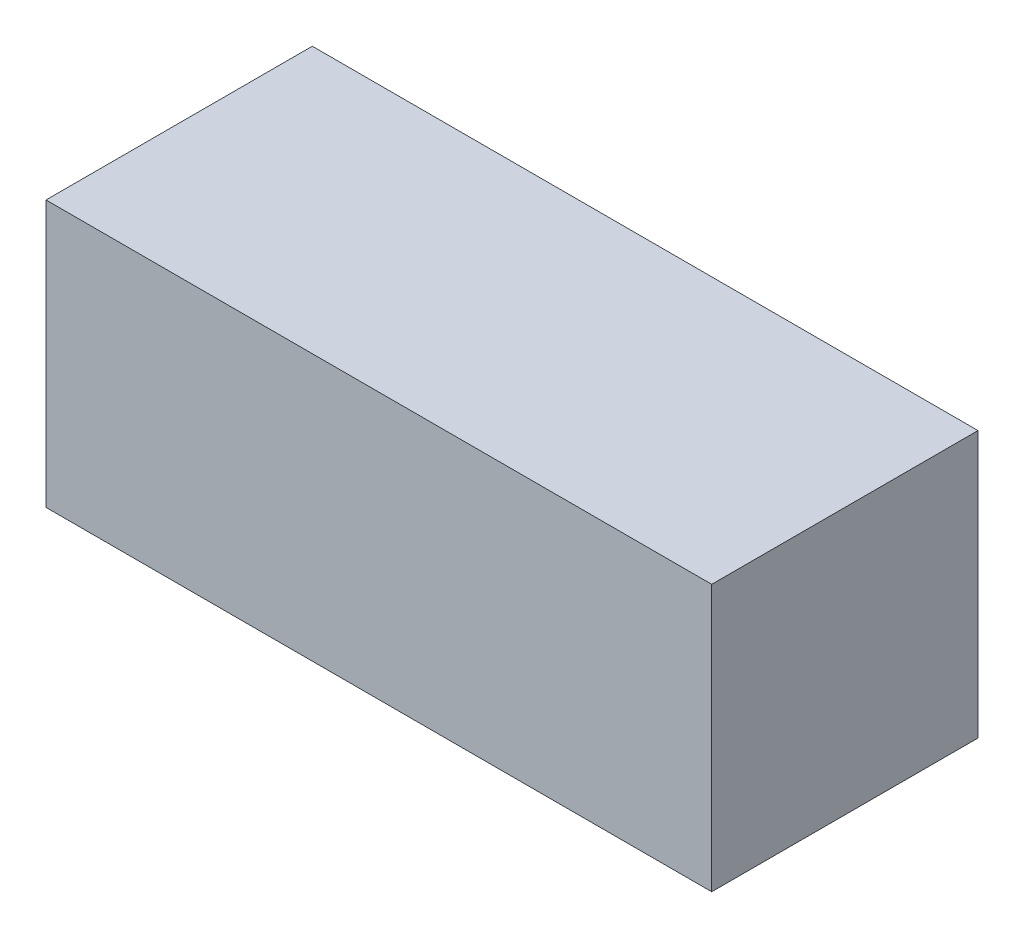
from build123d import *

# Parameters (mm, degrees)
SKETCH1_W           = 63.5
SKETCH1_H           = 25.4
BOSS_EXTRUDE1_DEPTH = 25.4


with BuildPart() as part:
    # Sketch1 → Boss-Extrude1 (new body)
    with BuildSketch(Plane(origin=(0, 0, 0), x_dir=(1, 0, 0), z_dir=(0, 1, 0))):
        with Locations((31.75, 12.7)):
            Rectangle(SKETCH1_W, SKETCH1_H)
    extrude(amount=BOSS_EXTRUDE1_DEPTH)


solid = part.part
